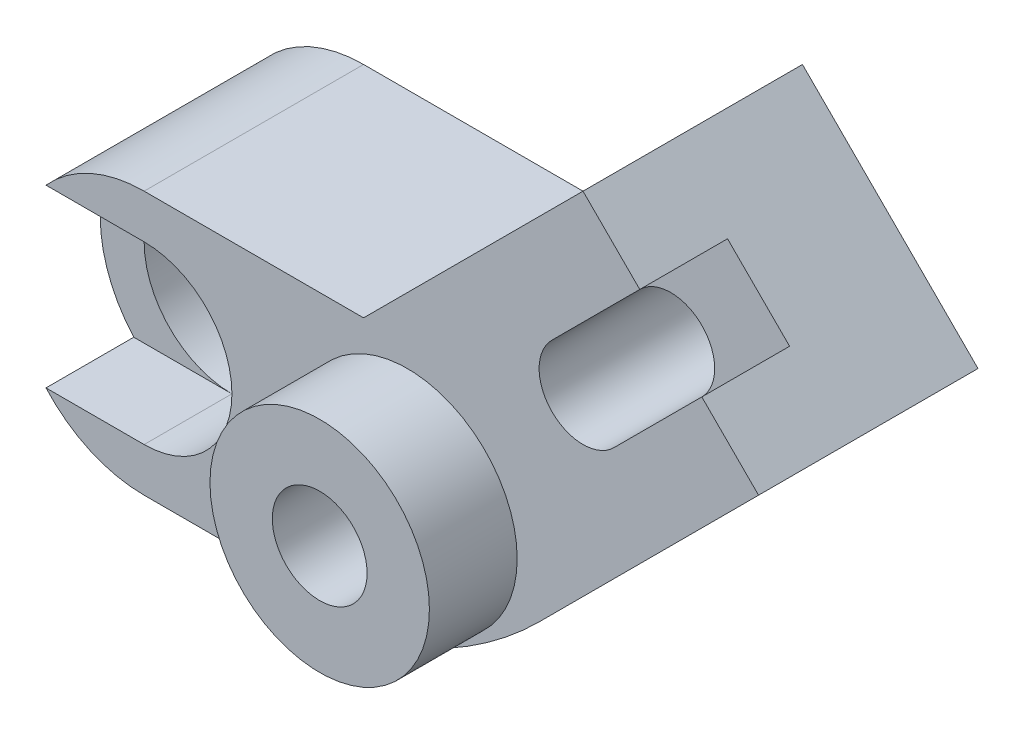
from build123d import *

# Parameters (mm, degrees)
BOSS_EXTRUDE2_DEPTH         = 25
SKETCH2_R                   = 5
CUT_EXTRUDE1_DEPTH          = 63
CUT_EXTRUDE2_DEPTH          = 10
SKETCH4_R                   = 12.5
BOSS_EXTRUDE4_DEPTH         = 10
SKETCH10_R                  = 10
CUT_EXTRUDE3_DEPTH          = 15
SKETCH11_R                  = 5
CUT_EXTRUDE4_DEPTH          = 872
CUT_EXTRUDE6_DEPTH          = 10
M12X1_25_TAPPED_HOLE1_D     = 10.8
M12X1_25_TAPPED_HOLE1_DEPTH = 15
M12X1_25_TAPPED_HOLE1_TIP   = 3.244647343


with BuildPart() as part:
    # Sketch1 → Boss-Extrude2 (new body)
    with BuildSketch(Plane.XY):
        with BuildLine():
            Line((-45, -5), (-20, 20))
            Line((-20, 20), (0, 0))
            Line((0, 0), (-25, -25))
            ThreePointArc((-25, -25), (-32.004902432, -30.742646352), (-40, -35))
            Line((-40, -35), (-70, -35))
            ThreePointArc((-70, -35), (-85, -20), (-70, -5))
            Line((-70, -5), (-45, -5))
        make_face()
    extrude(amount=BOSS_EXTRUDE2_DEPTH)

    # Sketch2 → Cut-Extrude1 (cut)
    with BuildSketch(Plane.XY.offset(25)):
        with Locations((-20, 0)):
            Circle(SKETCH2_R)
    extrude(amount=-CUT_EXTRUDE1_DEPTH, mode=Mode.SUBTRACT)

    # Sketch3 → Cut-Extrude2 (cut)
    with BuildSketch(Plane.XY.offset(25)):
        with BuildLine():
            Line((-6.464921114, 6.464921114), (-13.535078886, 13.535078886))
            Line((-13.535078886, 13.535078886), (-23.478357909, 3.591799863))
            ThreePointArc((-23.478357909, 3.591799863), (-18.049588447, 4.603899953), (-15, 0))
            ThreePointArc((-15, 0), (-15.365401888, -1.876299641), (-16.408200137, -3.478357909))
            Line((-16.408200137, -3.478357909), (-6.464921114, 6.464921114))
        make_face()
    extrude(amount=-CUT_EXTRUDE2_DEPTH, mode=Mode.SUBTRACT)

    # Sketch4 → Boss-Extrude4 (add)
    with BuildSketch(Plane.XY.offset(25)):
        with Locations((-40, -20)):
            Circle(SKETCH4_R)
    extrude(amount=BOSS_EXTRUDE4_DEPTH)

    # Sketch10 → Cut-Extrude3 (cut)
    with BuildSketch(Plane.XY.offset(25)):
        with Locations((-70, -20)):
            Circle(SKETCH10_R)
    extrude(amount=-CUT_EXTRUDE3_DEPTH, mode=Mode.SUBTRACT)

    # Sketch11 → Cut-Extrude4 (cut)
    with BuildSketch(Plane.XY.offset(10)):
        with Locations((-70, -20)):
            Circle(SKETCH11_R)
    extrude(amount=-CUT_EXTRUDE4_DEPTH, mode=Mode.SUBTRACT)

    # Sketch12 → Cut-Extrude6 (cut)
    with BuildSketch(Plane.XY.offset(25)):
        with BuildLine():
            Line((-70, -30), (-81.180339887, -30))
            ThreePointArc((-81.180339887, -30), (-85, -20), (-81.180339887, -10))
            Line((-81.180339887, -10), (-70, -10))
            ThreePointArc((-70, -10), (-80, -20), (-70, -30))
        make_face()
    extrude(amount=-CUT_EXTRUDE6_DEPTH, mode=Mode.SUBTRACT)

    # M12x1.25 Tapped Hole1
    with Locations(Plane.XY.offset(35)):
        with Locations((-40, -20)):
            Hole(M12X1_25_TAPPED_HOLE1_D / 2, depth=M12X1_25_TAPPED_HOLE1_DEPTH)
            with Locations((0, 0, -(M12X1_25_TAPPED_HOLE1_DEPTH + M12X1_25_TAPPED_HOLE1_TIP / 2))):  # 118° drill point
                Cone(0, M12X1_25_TAPPED_HOLE1_D / 2, M12X1_25_TAPPED_HOLE1_TIP, mode=Mode.SUBTRACT)


solid = part.part
